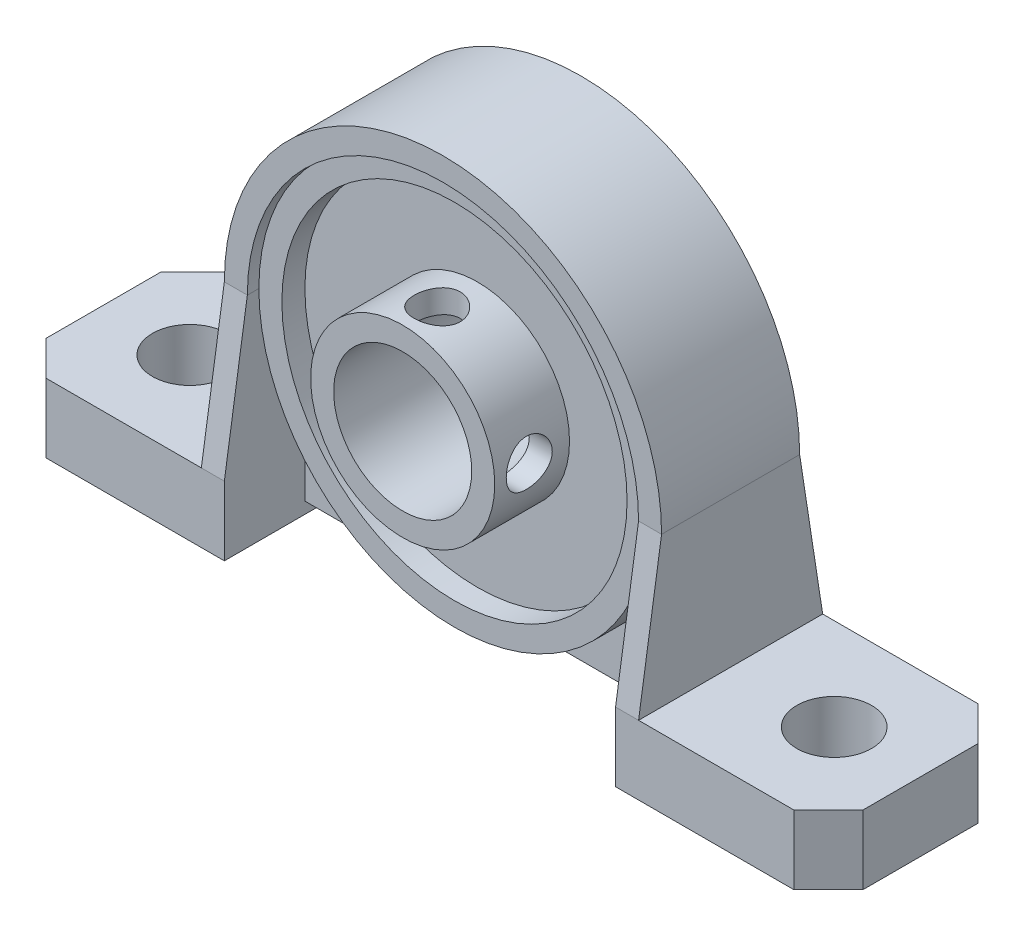
from build123d import *

# Parameters (mm, degrees)
BOSS_EXTRUDE1_DEPTH = 8
CHAMFER1_SIZE       = 3
SKETCH3_R           = 3.25
CUT_EXTRUDE2_DEPTH  = 19
SKETCH4_R           = 17
BOSS_EXTRUDE2_DEPTH = 3
SKETCH5_R           = 17
SKETCH5_R_2         = 15
BOSS_EXTRUDE3_DEPTH = 2
SKETCH6_R           = 8
BOSS_EXTRUDE4_DEPTH = 6.5
SKETCH7_R           = 8
BOSS_EXTRUDE5_DEPTH = 3
SKETCH8_R           = 6
CUT_EXTRUDE3_DEPTH  = 23
BOSS_EXTRUDE6_REACH = 39
SKETCH9_W           = 34
SKETCH9_H           = 2
CUT_EXTRUDE4_DEPTH  = 2
SKETCH11_W          = 2
SKETCH11_H          = 2
CUT_REVOLVE1_ANGLE  = 180
SKETCH12_R          = 2
CUT_EXTRUDE5_DEPTH  = 12
SKETCH13_R          = 2
CUT_EXTRUDE6_DEPTH  = 4


with BuildPart() as part:
    # Sketch1 → Boss-Extrude1 (new body, symmetric)
    with BuildSketch(Plane.XY):
        with BuildLine():
            Line((-35.5, 3), (-19, 3))
            Line((-19, 3), (-19, 16))
            ThreePointArc((-19, 16), (0, 35), (19, 16))
            Line((19, 16), (19, 3))
            Line((19, 3), (35.5, 3))
            Line((35.5, 3), (35.5, -3))
            Line((35.5, -3), (17, -3))
            Line((17, -3), (17, 16))
            ThreePointArc((17, 16), (0, 33), (-17, 16))
            Line((-17, 16), (-17, -3))
            Line((-17, -3), (-35.5, -3))
            Line((-35.5, -3), (-35.5, 3))
        make_face()
    extrude(amount=BOSS_EXTRUDE1_DEPTH, both=True)

    # Chamfer1
    chamfer1_edges = [part.edges().sort_by_distance(p)[0] for p in [
        (-35.5, 0, -8),
        (35.5, 0, -8),
        (-35.5, 0, 8),
        (35.5, 0, 8),
    ]]
    chamfer(chamfer1_edges, length=CHAMFER1_SIZE)

    # Sketch3 → Cut-Extrude2 (cut)
    with BuildSketch(Plane(origin=(0, 3, 0), x_dir=(1, 0, 0), z_dir=(0, 1, 0))):
        with Locations((28, 0)):
            Circle(SKETCH3_R)
        with Locations((-28, 0)):
            Circle(SKETCH3_R)
    extrude(amount=-CUT_EXTRUDE2_DEPTH, mode=Mode.SUBTRACT)

    # Sketch4 → Boss-Extrude2 (add, symmetric)
    with BuildSketch(Plane.XY):
        with Locations((0, 16)):
            Circle(SKETCH4_R)
    extrude(amount=BOSS_EXTRUDE2_DEPTH, both=True)

    # Sketch5 → Boss-Extrude3 (add)
    with BuildSketch(Plane.XY.offset(3)):
        with Locations((0, 16)):
            Circle(SKETCH5_R)
        with Locations((0, 16)):
            Circle(SKETCH5_R_2, mode=Mode.SUBTRACT)
    boss_extrude3 = extrude(amount=BOSS_EXTRUDE3_DEPTH)

    # Mirror1: Boss-Extrude3 across plane
    add(boss_extrude3.mirror(Plane.XY))

    # Sketch6 → Boss-Extrude4 (add)
    with BuildSketch(Plane.XY.offset(3)):
        with Locations((0, 16)):
            Circle(SKETCH6_R)
    extrude(amount=BOSS_EXTRUDE4_DEPTH)

    # Sketch7 → Boss-Extrude5 (add)
    with BuildSketch(Plane(origin=(0, 0, -3), x_dir=(-1, 0, 0), z_dir=(0, 0, -1))):
        with Locations((0, 16)):
            Circle(SKETCH7_R)
    extrude(amount=BOSS_EXTRUDE5_DEPTH)

    # Sketch8 → Cut-Extrude3 (cut)
    with BuildSketch(Plane.XY.offset(9.5)):
        with Locations((0, 16)):
            Circle(SKETCH8_R)
    extrude(amount=-CUT_EXTRUDE3_DEPTH, mode=Mode.SUBTRACT)

    # Sketch9 → Boss-Extrude6 (add, up to next)
    with BuildSketch(Plane(origin=(0, -2, 0), x_dir=(1, 0, 0), z_dir=(0, 1, 0)), mode=Mode.PRIVATE) as boss_extrude6_sk1:
        Rectangle(SKETCH9_W, SKETCH9_H)
    boss_extrude6_tool1 = extrude(boss_extrude6_sk1.sketch, amount=BOSS_EXTRUDE6_REACH, mode=Mode.PRIVATE) - part.part
    add(boss_extrude6_tool1.solids().sort_by_distance((0, -2, 0))[0])

    # Sketch10 → Cut-Extrude4 (cut)
    with BuildSketch(Plane(origin=(19, 0, 0), x_dir=(0, 0, -1), z_dir=(1, 0, 0))):
        Polygon((-8, 3), (-8, 16), (-6, 16), align=None)
        Polygon((6, 16), (8, 3), (8, 16), align=None)
    cut_extrude4 = extrude(amount=-CUT_EXTRUDE4_DEPTH, mode=Mode.SUBTRACT)

    # Mirror2: Cut-Extrude4 across plane
    add(cut_extrude4.mirror(Plane(origin=(0, 0, 0), x_dir=(0, 0, 1), z_dir=(1, 0, 0))), mode=Mode.SUBTRACT)

    # Sketch11 → Cut-Revolve1 (revolve, cut)
    with BuildSketch(Plane.XZ.offset(-16)):
        with Locations((-18, 7)):
            Rectangle(SKETCH11_W, SKETCH11_H)
        with Locations((-18, -7)):
            Rectangle(SKETCH11_W, SKETCH11_H)
    revolve(axis=Axis((0, 16, 3), (0, 0, -1)), revolution_arc=CUT_REVOLVE1_ANGLE, mode=Mode.SUBTRACT)

    # Sketch12 → Cut-Extrude5 (cut)
    with BuildSketch(Plane(origin=(0, 0, 0), x_dir=(0, 0, -1), z_dir=(1, 0, 0))):
        with Locations((-6.5, 16)):
            Circle(SKETCH12_R)
    extrude(amount=CUT_EXTRUDE5_DEPTH, mode=Mode.SUBTRACT)

    # Sketch13 → Cut-Extrude6 (cut)
    with BuildSketch(Plane(origin=(0, 20, 0), x_dir=(1, 0, 0), z_dir=(0, 1, 0))):
        with Locations((0, -6.5)):
            Circle(SKETCH13_R)
    extrude(amount=CUT_EXTRUDE6_DEPTH, mode=Mode.SUBTRACT)


solid = part.part
